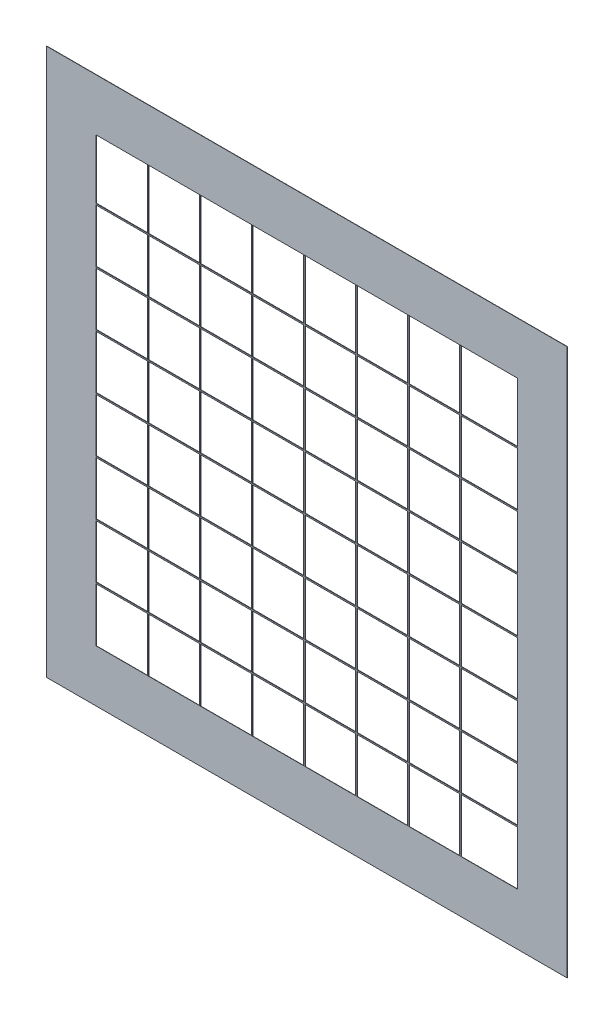
from build123d import *

# Parameters (mm, degrees)
SKETCH_2_W           = 200
SKETCH_2_H           = 210
SKETCH_2_W_2         = 161.904761904
SKETCH_2_H_2         = 170
EXTRUDE_1_DEPTH      = 0.1
SKETCH_3_W           = 0.5
SKETCH_3_H           = 170
EXTRUDE_1_2_DEPTH    = 0.2
EXTRUDE_1_2_2_DEPTH  = 0.2
EXTRUDE_1_2_3_DEPTH  = 0.2
EXTRUDE_1_2_4_DEPTH  = 0.2
EXTRUDE_1_2_5_DEPTH  = 0.2
EXTRUDE_1_2_6_DEPTH  = 0.2
EXTRUDE_1_2_7_DEPTH  = 0.2
SKETCH_3_W_2         = 161.904761904
SKETCH_3_H_2         = 0.5
EXTRUDE_1_2_8_DEPTH  = 0.2
EXTRUDE_1_2_9_DEPTH  = 0.2
EXTRUDE_1_2_10_DEPTH = 0.2
EXTRUDE_1_2_11_DEPTH = 0.2
EXTRUDE_1_2_12_DEPTH = 0.2
EXTRUDE_1_2_13_DEPTH = 0.2
EXTRUDE_1_2_14_DEPTH = 0.2


with BuildPart() as part:
    # 草图2 → Extrude 1 (new body)
    with BuildSketch(Plane.XY):
        with Locations((105, -136.893726012)):
            Rectangle(SKETCH_2_W, SKETCH_2_H)
        with Locations((105, -136.893726012)):
            Rectangle(SKETCH_2_W_2, SKETCH_2_H_2, mode=Mode.SUBTRACT)
    extrude(amount=EXTRUDE_1_DEPTH)


with BuildPart() as body_2:
    # 草图3 → Extrude 1 2 (new body)
    with BuildSketch(Plane.XY):
        with Locations((44.047619048, -136.893726012)):
            Rectangle(SKETCH_3_W, SKETCH_3_H)
    extrude(amount=EXTRUDE_1_2_DEPTH)


with BuildPart() as body_3:
    # 草图3 → Extrude 1 2 2 (new body)
    with BuildSketch(Plane.XY):
        with Locations((64.047619048, -136.893726012)):
            Rectangle(SKETCH_3_W, SKETCH_3_H)
    extrude(amount=EXTRUDE_1_2_2_DEPTH)


with BuildPart() as body_4:
    # 草图3 → Extrude 1 2 3 (new body)
    with BuildSketch(Plane.XY):
        with Locations((84.047619048, -136.893726012)):
            Rectangle(SKETCH_3_W, SKETCH_3_H)
    extrude(amount=EXTRUDE_1_2_3_DEPTH)


with BuildPart() as body_5:
    # 草图3 → Extrude 1 2 4 (new body)
    with BuildSketch(Plane.XY):
        with Locations((104.047619048, -136.893726012)):
            Rectangle(SKETCH_3_W, SKETCH_3_H)
    extrude(amount=EXTRUDE_1_2_4_DEPTH)


with BuildPart() as body_6:
    # 草图3 → Extrude 1 2 5 (new body)
    with BuildSketch(Plane.XY):
        with Locations((124.047619048, -136.893726012)):
            Rectangle(SKETCH_3_W, SKETCH_3_H)
    extrude(amount=EXTRUDE_1_2_5_DEPTH)


with BuildPart() as body_7:
    # 草图3 → Extrude 1 2 6 (new body)
    with BuildSketch(Plane.XY):
        with Locations((144.047619048, -136.893726012)):
            Rectangle(SKETCH_3_W, SKETCH_3_H)
    extrude(amount=EXTRUDE_1_2_6_DEPTH)


with BuildPart() as body_8:
    # 草图3 → Extrude 1 2 7 (new body)
    with BuildSketch(Plane.XY):
        with Locations((164.047619048, -136.893726012)):
            Rectangle(SKETCH_3_W, SKETCH_3_H)
    extrude(amount=EXTRUDE_1_2_7_DEPTH)


with BuildPart() as body_9:
    # 草图3 → Extrude 1 2 8 (new body)
    with BuildSketch(Plane.XY):
        with Locations((105, -200.893726012)):
            Rectangle(SKETCH_3_W_2, SKETCH_3_H_2)
    extrude(amount=EXTRUDE_1_2_8_DEPTH)


with BuildPart() as body_10:
    # 草图3 → Extrude 1 2 9 (new body)
    with BuildSketch(Plane.XY):
        with Locations((105, -179.893726012)):
            Rectangle(SKETCH_3_W_2, SKETCH_3_H_2)
    extrude(amount=EXTRUDE_1_2_9_DEPTH)


with BuildPart() as body_11:
    # 草图3 → Extrude 1 2 10 (new body)
    with BuildSketch(Plane.XY):
        with Locations((105, -158.893726012)):
            Rectangle(SKETCH_3_W_2, SKETCH_3_H_2)
    extrude(amount=EXTRUDE_1_2_10_DEPTH)


with BuildPart() as body_12:
    # 草图3 → Extrude 1 2 11 (new body)
    with BuildSketch(Plane.XY):
        with Locations((105, -137.893726012)):
            Rectangle(SKETCH_3_W_2, SKETCH_3_H_2)
    extrude(amount=EXTRUDE_1_2_11_DEPTH)


with BuildPart() as body_13:
    # 草图3 → Extrude 1 2 12 (new body)
    with BuildSketch(Plane.XY):
        with Locations((105, -116.893726012)):
            Rectangle(SKETCH_3_W_2, SKETCH_3_H_2)
    extrude(amount=EXTRUDE_1_2_12_DEPTH)


with BuildPart() as body_14:
    # 草图3 → Extrude 1 2 13 (new body)
    with BuildSketch(Plane.XY):
        with Locations((105, -95.893726012)):
            Rectangle(SKETCH_3_W_2, SKETCH_3_H_2)
    extrude(amount=EXTRUDE_1_2_13_DEPTH)


with BuildPart() as body_15:
    # 草图3 → Extrude 1 2 14 (new body)
    with BuildSketch(Plane.XY):
        with Locations((105, -74.893726012)):
            Rectangle(SKETCH_3_W_2, SKETCH_3_H_2)
    extrude(amount=EXTRUDE_1_2_14_DEPTH)


solid = Compound([part.part, body_2.part, body_3.part, body_4.part, body_5.part, body_6.part, body_7.part, body_8.part, body_9.part, body_10.part, body_11.part, body_12.part, body_13.part, body_14.part, body_15.part])
